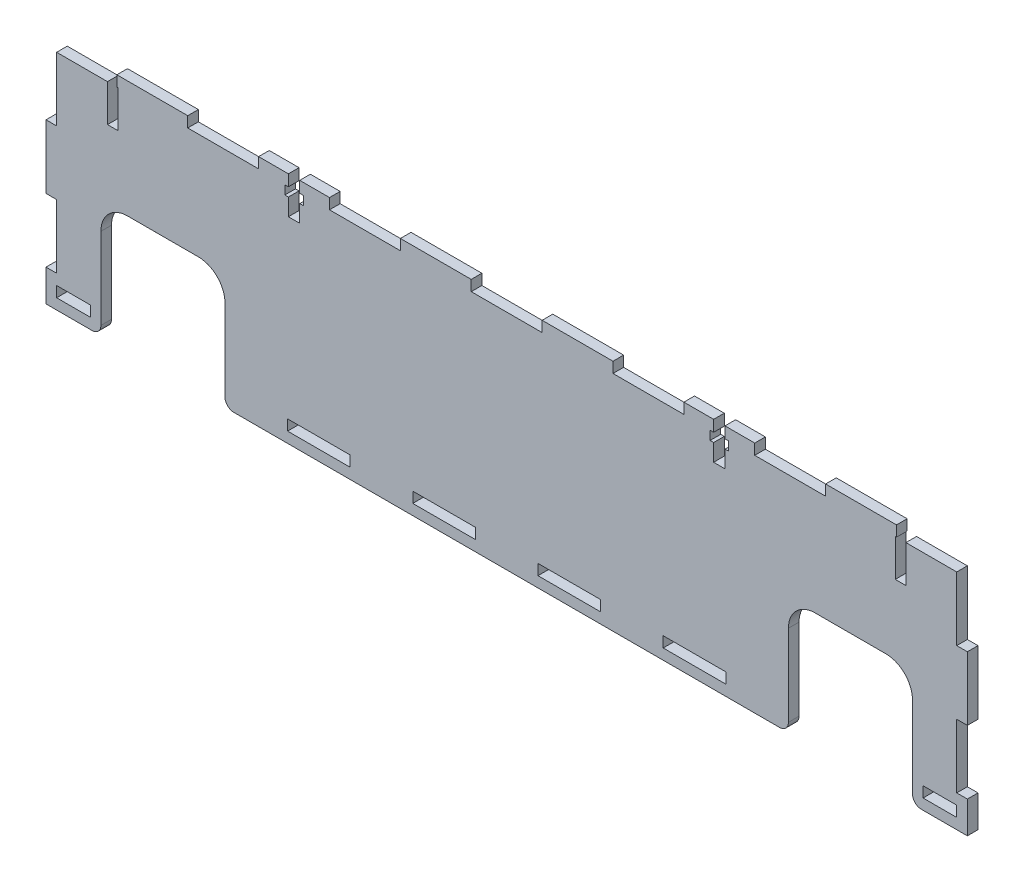
from build123d import *

# Parameters (mm, degrees)
BOSS_EXTRUDE1_DEPTH     = 3
SKETCH2_W               = 3
SKETCH2_H               = 18
SKETCH2_W_2             = 17.666666666
SKETCH2_H_2             = 3
SKETCH2_W_3             = 17.666666667
SKETCH2_W_4             = 9.5
SKETCH2_W_5             = 20
CUT_EXTRUDE1_DEPTH      = 1
CUT_EXTRUDE1_DEPTH_BACK = 4
SKETCH3_W               = 3.2
SKETCH3_H               = 10.5
SKETCH3_W_2             = 5.2
SKETCH3_H_2             = 2.5
CUT_EXTRUDE2_DEPTH      = 1
CUT_EXTRUDE2_DEPTH_BACK = 4
FILLET1_R               = 7.5
FILLET2_R               = 2.5
SKETCH4_W               = 3
SKETCH4_H               = 10.5
CUT_EXTRUDE3_DEPTH      = 4
CUT_EXTRUDE3_DEPTH_BACK = 1


with BuildPart() as part:
    # Sketch1 → Boss-Extrude1 (new body)
    with BuildSketch(Plane.XY):
        Polygon((-130, 33), (130, 33), (130, -33), (114.5, -33), (114.5, 0), (79.5, 0), (79.5, -33), (-79.5, -33), (-79.5, 0), (-114.5, 0), (-114.5, -33), (-130, -33), align=None)
    extrude(amount=BOSS_EXTRUDE1_DEPTH)

    # Sketch2 → Cut-Extrude1 (cut, two sides)
    with BuildSketch(Plane.XY.offset(3)) as cut_extrude1_sk:
        with Locations((-128.5, 21)):
            Rectangle(SKETCH2_W, SKETCH2_H)
        with Locations((-128.5, -15)):
            Rectangle(SKETCH2_W, SKETCH2_H)
        with Locations((-53, -28.5)):
            Rectangle(SKETCH2_W_2, SKETCH2_H_2)
        with Locations((-17.666666666, -28.5)):
            Rectangle(SKETCH2_W_3, SKETCH2_H_2)
        with Locations((17.666666666, -28.5)):
            Rectangle(SKETCH2_W_3, SKETCH2_H_2)
        with Locations((53, -28.5)):
            Rectangle(SKETCH2_W_2, SKETCH2_H_2)
        with Locations((122.25, -28.5)):
            Rectangle(SKETCH2_W_4, SKETCH2_H_2)
        with Locations((128.5, -15)):
            Rectangle(SKETCH2_W, SKETCH2_H)
        with Locations((128.5, 21)):
            Rectangle(SKETCH2_W, SKETCH2_H)
        Polygon((130, 33), (110, 33), (110, 30), (127, 30), (130, 30), align=None)
        with Locations((80, 31.5)):
            Rectangle(SKETCH2_W_5, SKETCH2_H_2)
        with Locations((40, 31.5)):
            Rectangle(SKETCH2_W_5, SKETCH2_H_2)
        with Locations((-40, 31.5)):
            Rectangle(SKETCH2_W_5, SKETCH2_H_2)
        with Locations((-80, 31.5)):
            Rectangle(SKETCH2_W_5, SKETCH2_H_2)
        with Locations((0, 31.5)):
            Rectangle(SKETCH2_W_5, SKETCH2_H_2)
        with Locations((-120, 31.5)):
            Rectangle(SKETCH2_W_5, SKETCH2_H_2)
        with Locations((-122.25, -28.5)):
            Rectangle(SKETCH2_W_4, SKETCH2_H_2)
    extrude(amount=CUT_EXTRUDE1_DEPTH, mode=Mode.SUBTRACT)
    extrude(cut_extrude1_sk.sketch, amount=-CUT_EXTRUDE1_DEPTH_BACK, mode=Mode.SUBTRACT)

    # Sketch3 → Cut-Extrude2 (cut, two sides)
    with BuildSketch(Plane.XY.offset(3)) as cut_extrude2_sk:
        with Locations((-60, 27.75)):
            Rectangle(SKETCH3_W, SKETCH3_H)
        with Locations((60, 27.75)):
            Rectangle(SKETCH3_W, SKETCH3_H)
        with Locations((-60, 28.575)):
            Rectangle(SKETCH3_W_2, SKETCH3_H_2)
        with Locations((60, 28.575)):
            Rectangle(SKETCH3_W_2, SKETCH3_H_2)
    extrude(amount=CUT_EXTRUDE2_DEPTH, mode=Mode.SUBTRACT)
    extrude(cut_extrude2_sk.sketch, amount=-CUT_EXTRUDE2_DEPTH_BACK, mode=Mode.SUBTRACT)

    # Fillet1
    fillet1_edges = [part.edges().sort_by_distance(p)[0] for p in [
        (114.5, 0, 1.5),
        (79.5, 0, 1.5),
        (-79.5, 0, 1.5),
        (-114.5, 0, 1.5),
    ]]
    fillet(fillet1_edges, radius=FILLET1_R)

    # Fillet2
    fillet2_edges = [part.edges().sort_by_distance(p)[0] for p in [
        (114.5, -33, 1.5),
        (79.5, -33, 1.5),
        (-79.5, -33, 1.5),
        (-114.5, -33, 1.5),
    ]]
    fillet(fillet2_edges, radius=FILLET2_R)

    # Sketch4 → Cut-Extrude3 (cut, two sides)
    with BuildSketch(Plane.XY) as cut_extrude3_sk:
        with Locations((-111.15, 24.75)):
            Rectangle(SKETCH4_W, SKETCH4_H)
        with Locations((111.15, 24.75)):
            Rectangle(SKETCH4_W, SKETCH4_H)
    extrude(amount=CUT_EXTRUDE3_DEPTH, mode=Mode.SUBTRACT)
    extrude(cut_extrude3_sk.sketch, amount=-CUT_EXTRUDE3_DEPTH_BACK, mode=Mode.SUBTRACT)


solid = part.part
